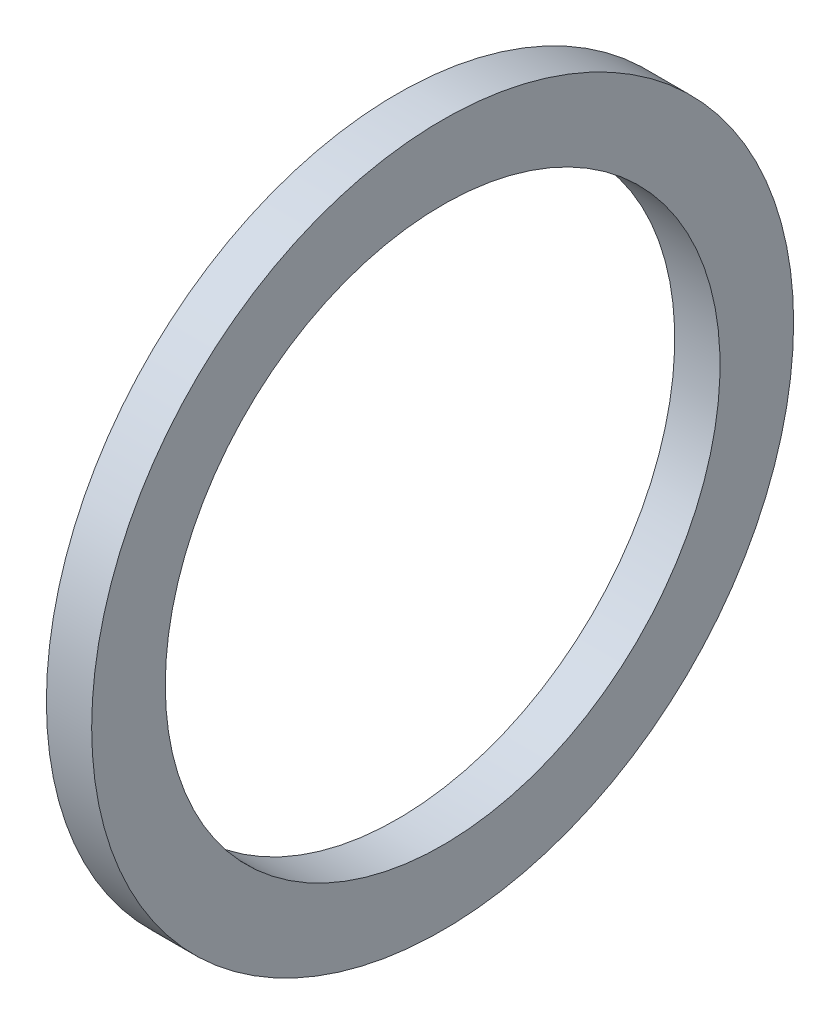
from build123d import *

# Parameters (mm, degrees)
SKETCH1_W = 2.032
SKETCH1_H = 3.302


with BuildPart() as part:
    # Sketch1 → Revolve1 (revolve)
    with BuildSketch(Plane.XY, mode=Mode.PRIVATE) as revolve1_sk:
        with Locations((1.016, -14.097)):
            Rectangle(SKETCH1_W, SKETCH1_H)
    revolve(revolve1_sk.sketch.rotate(Axis((-43.716580756, 0, 0), (1, 0, 0)), 270), axis=Axis((-43.716580756, 0, 0), (1, 0, 0)))  # turned: the seam where the file's is


solid = part.part
